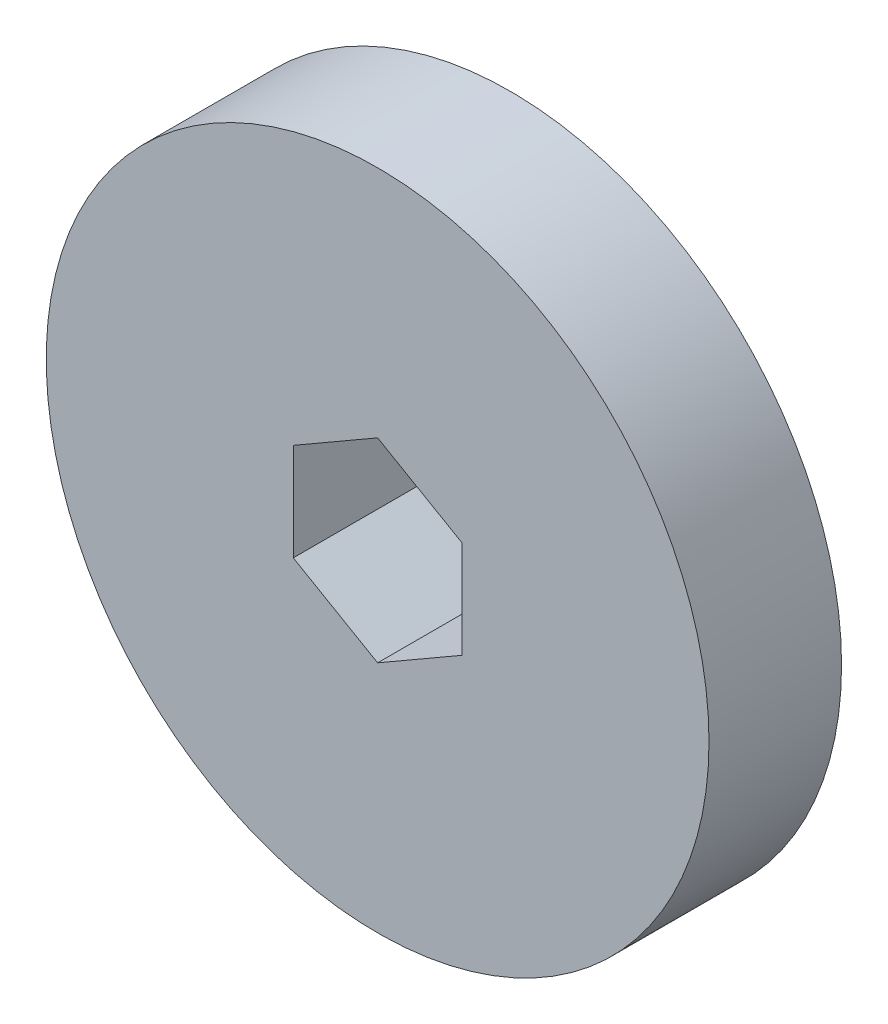
from build123d import *

# Parameters (mm, degrees)
SKETCH1_R           = 25
BOSS_EXTRUDE2_DEPTH = 10
CUT_EXTRUDE1_DEPTH  = 10


with BuildPart() as part:
    # Sketch1 → Boss-Extrude2 (new body)
    with BuildSketch(Plane.XY):
        Circle(SKETCH1_R)
    extrude(amount=BOSS_EXTRUDE2_DEPTH)

    # Sketch2 → Cut-Extrude1 (cut)
    with BuildSketch(Plane.XY.offset(10)):
        Polygon((0, 7.349668927), (-6.365, 3.674834463), (-6.365, -3.674834463), (0, -7.349668927), (6.365, -3.674834463), (6.365, 3.674834463), align=None)
    extrude(amount=-CUT_EXTRUDE1_DEPTH, mode=Mode.SUBTRACT)


solid = part.part
